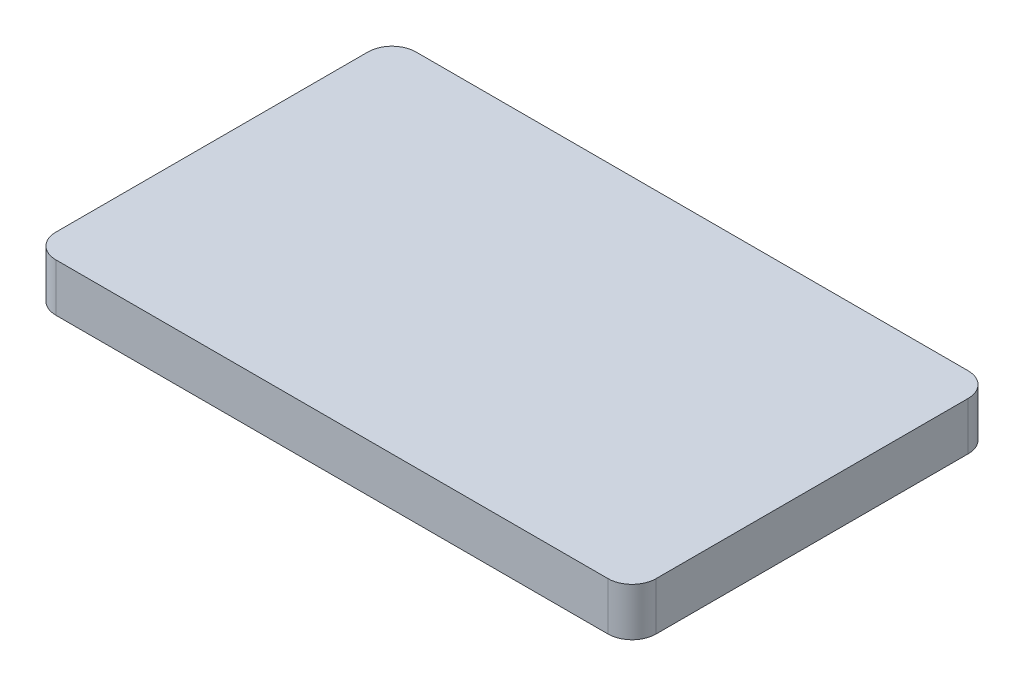
from build123d import *

# Parameters (mm, degrees)
SKETCH_1_W      = 250
SKETCH_1_H      = 150
EXTRUDE_1_DEPTH = 20
FILLET_1_R      = 10


with BuildPart() as part:
    # 草图1 → 凸台-拉伸1 (new body)
    with BuildSketch(Plane(origin=(0, 0, 0), x_dir=(1, 0, 0), z_dir=(0, 1, 0))):
        Rectangle(SKETCH_1_W, SKETCH_1_H)
    extrude(amount=EXTRUDE_1_DEPTH)

    # 圆角1
    fillet_1_edges = [part.edges().sort_by_distance(p)[0] for p in [
        (125, 10, 75),
        (-125, 10, 75),
        (-125, 10, -75),
        (125, 10, -75),
    ]]
    fillet(fillet_1_edges, radius=FILLET_1_R)


solid = part.part
